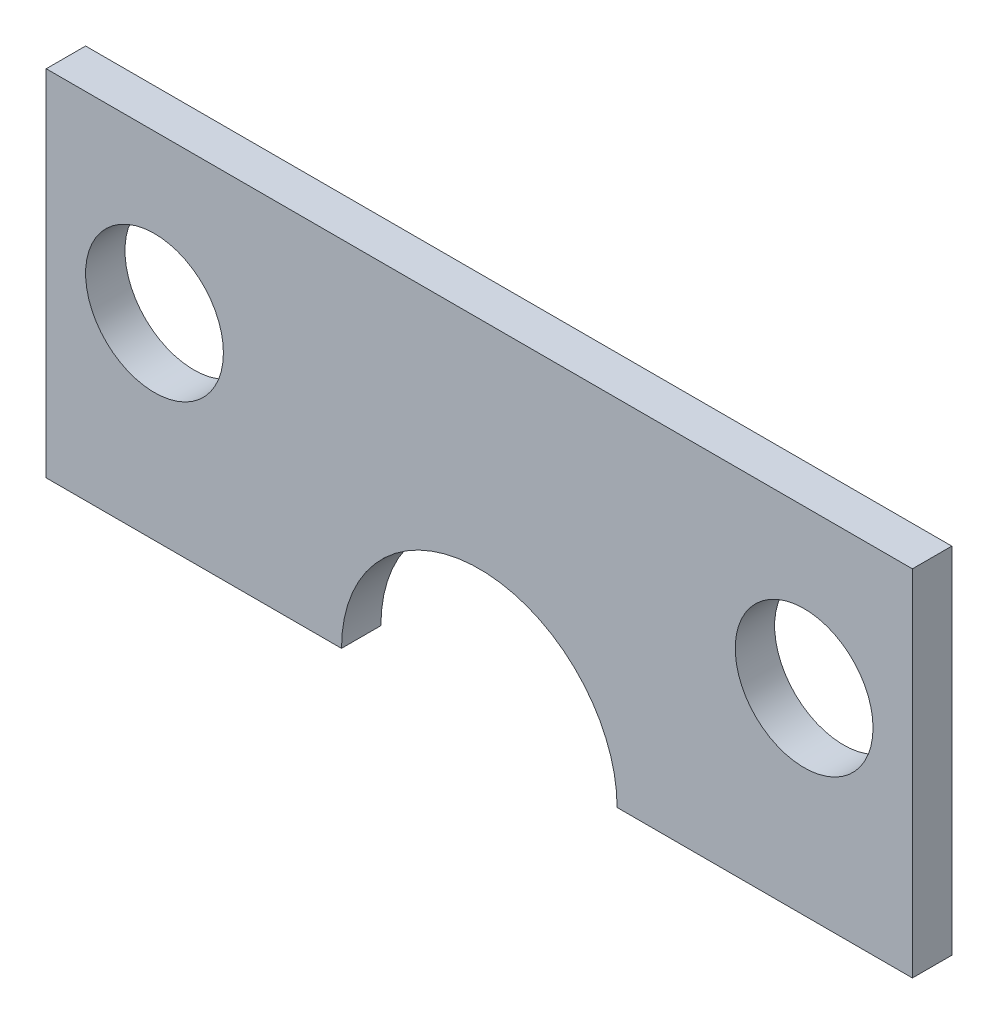
from build123d import *

# Parameters (mm, degrees)
SKETCH1_W               = 44
SKETCH1_H               = 18
BOSS_EXTRUDE1_DEPTH     = 2
CUT_EXTRUDE3_DEPTH      = 1
CUT_EXTRUDE3_DEPTH_BACK = 2
SKETCH8_R               = 3.5
CUT_EXTRUDE4_DEPTH      = 2.8
SKETCH9_R               = 3.5
CUT_EXTRUDE5_DEPTH      = 2.8


with BuildPart() as part:
    # Sketch1 → Boss-Extrude1 (new body)
    with BuildSketch(Plane.XY):
        with Locations((-52.289658906, -63.346772489)):
            Rectangle(SKETCH1_W, SKETCH1_H)
    extrude(amount=-BOSS_EXTRUDE1_DEPTH)

    # Sketch7 → Cut-Extrude3 (cut, two sides)
    with BuildSketch(Plane.XY) as cut_extrude3_sk:
        with BuildLine():
            Line((-45.289658906, -150.610965153), (-45.289658906, -72.346772489))
            ThreePointArc((-45.289658906, -72.346772489), (-52.289658906, -65.346772489), (-59.289658906, -72.346772489))
            Line((-59.289658906, -72.346772489), (-59.289658906, -150.610965153))
            Line((-59.289658906, -150.610965153), (-59.289658906, -307.13935048))
            Line((-59.289658906, -307.13935048), (-45.289658906, -307.13935048))
            Line((-45.289658906, -307.13935048), (-45.289658906, -150.610965153))
        make_face()
    extrude(amount=CUT_EXTRUDE3_DEPTH, mode=Mode.SUBTRACT)
    extrude(cut_extrude3_sk.sketch, amount=-CUT_EXTRUDE3_DEPTH_BACK, mode=Mode.SUBTRACT)

    # Sketch8 → Cut-Extrude4 (cut)
    with BuildSketch(Plane.XY):
        with Locations((-68.789658906, -62.346772489)):
            Circle(SKETCH8_R)
    extrude(amount=-CUT_EXTRUDE4_DEPTH, mode=Mode.SUBTRACT)

    # Sketch9 → Cut-Extrude5 (cut)
    with BuildSketch(Plane.XY):
        with Locations((-35.789658906, -62.346772489)):
            Circle(SKETCH9_R)
    extrude(amount=-CUT_EXTRUDE5_DEPTH, mode=Mode.SUBTRACT)


solid = part.part
